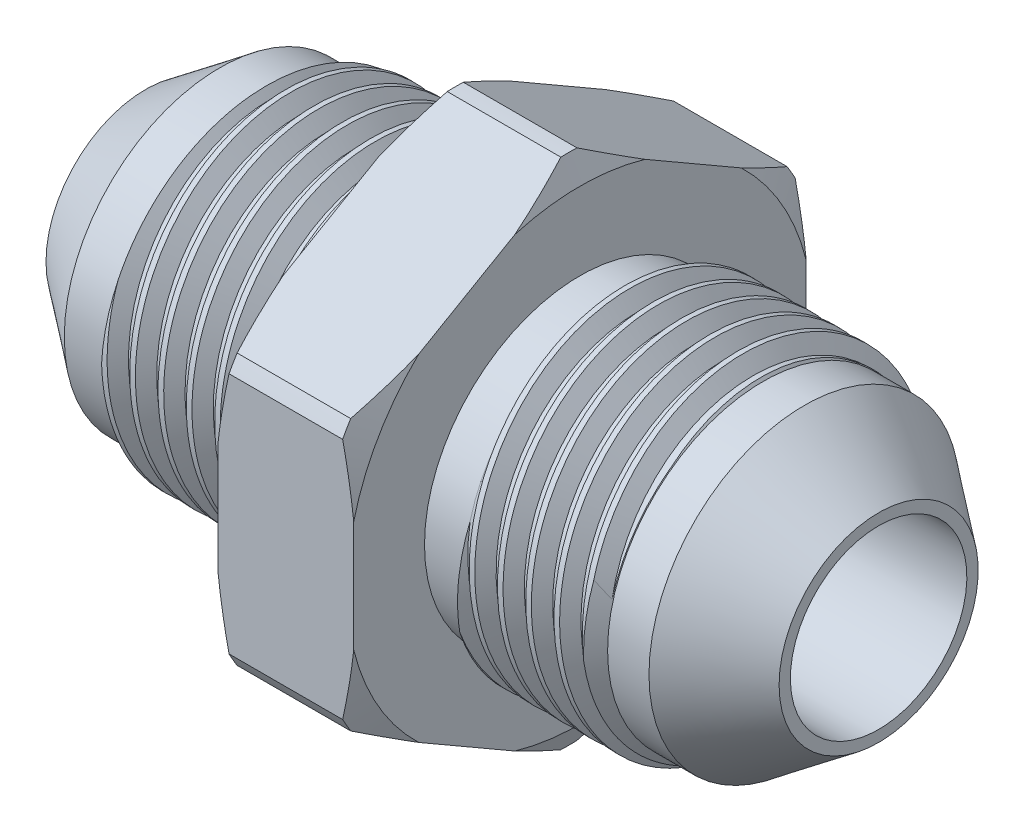
from build123d import *

# Parameters (mm, degrees)
SKETCH6_W           = 41.148
SKETCH6_H           = 9.525
LPATTERN4_COUNT     = 26
LPATTERN4_PITCH     = 1.5875
LPATTERN4_COL_COUNT = 2
LPATTERN4_COL_PITCH = 1.5875
EXTRUDE1_DEPTH      = 7.62
SKETCH7_W           = 41.148
SKETCH7_H           = 4.953
SKETCH11_W          = 2.321801
SKETCH11_H          = 2.54


with BuildPart() as part:
    # Sketch6 → Revolve3 (revolve)
    with BuildSketch(Plane.XY):
        with Locations((0, 4.7625)):
            Rectangle(SKETCH6_W, SKETCH6_H)
    revolve(axis=Axis((-20.574, 0, 0), (1, 0, 0)))

    # Sketch9 → Cut-Revolve4 (revolve, cut)
    with BuildSketch(Plane.XY):
        Polygon((-20.376248, 9.541479), (-18.991984, 9.656835), (-19.415006, 8.759345), (-19.81051, 8.726386), align=None)
    cut_revolve4 = revolve(axis=Axis((-20.574, -0.140818, 0), (0.996546, 0.083045, 0)), mode=Mode.SUBTRACT)

    # LPattern4: Cut-Revolve4 ×26
    with Locations(*[(i * LPATTERN4_PITCH, 0, 0) for i in range(1, LPATTERN4_COUNT)]):
        add(cut_revolve4, mode=Mode.SUBTRACT)

    # LPattern4 col: Cut-Revolve4 ×2
    with Locations(*[(-i * LPATTERN4_COL_PITCH, 0, 0) for i in range(1, LPATTERN4_COL_COUNT)]):
        add(cut_revolve4, mode=Mode.SUBTRACT)

    # Sketch12 → Extrude1 (add)
    with BuildSketch(Plane(origin=(-3.81, 0, 0), x_dir=(0, 0, -1), z_dir=(1, 0, 0))):
        Polygon((0, 14.664697), (-12.7, 7.332348), (-12.7, -7.332348), (0, -14.664697), (12.7, -7.332348), (12.7, 7.332348), align=None)
    extrude(amount=EXTRUDE1_DEPTH)

    # Sketch7 → Cut-Revolve5 (revolve, cut)
    with BuildSketch(Plane.XY):
        with Locations((0, 2.4765)):
            Rectangle(SKETCH7_W, SKETCH7_H)
    revolve(axis=Axis((20.574, 0, 0), (-1, 0, 0)), mode=Mode.SUBTRACT)

    # Sketch10 → Cut-Revolve6 (revolve, cut)
    with BuildSketch(Plane.XY):
        Polygon((20.574, 5.588), (20.574, 9.525), (13.53312, 9.525), (14.08742, 8.726386), (16.409221, 8.726386), align=None)
        Polygon((-20.574, 5.588), (-20.574, 9.525), (-13.53312, 9.525), (-14.08742, 8.726386), (-16.409221, 8.726386), align=None)
    revolve(axis=Axis((-20.574, 0, 0), (1, 0, 0)), mode=Mode.SUBTRACT)

    # Sketch13 → Cut-Revolve7 (revolve, cut)
    with BuildSketch(Plane.XY):
        Polygon((-3.81, 14.664697), (-3.81, 13.077197), (-3.188179, 14.410697), (3.188179, 14.410697), (3.81, 13.077197), (3.81, 14.664697), align=None)
    revolve(axis=Axis((-20.574, 0, 0), (1, 0, 0)), mode=Mode.SUBTRACT)

    # Sketch11 → Cut-Revolve9 (revolve, cut)
    with BuildSketch(Plane.XY):
        with Locations((-4.9709, 9.996386)):
            Rectangle(SKETCH11_W, SKETCH11_H)
        with Locations((4.9709, 9.996386)):
            Rectangle(SKETCH11_W, SKETCH11_H)
    revolve(axis=Axis((-20.574, 0, 0), (1, 0, 0)), mode=Mode.SUBTRACT)


solid = part.part
